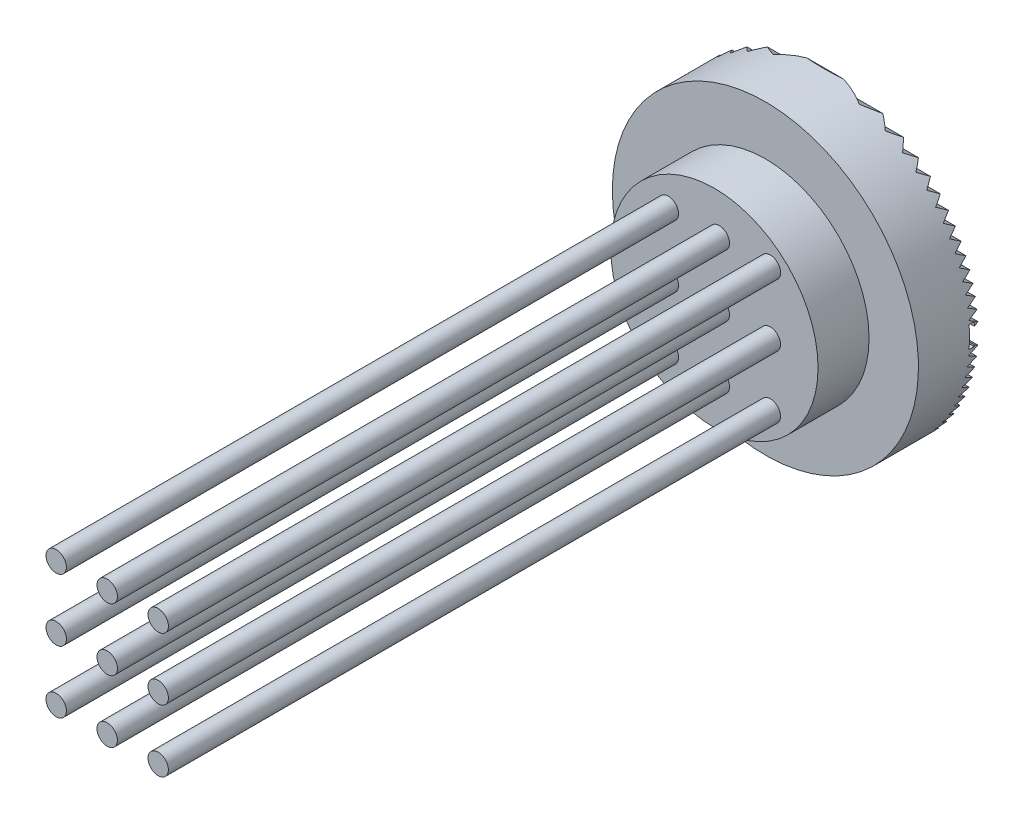
from build123d import *

# Parameters (mm, degrees)
SKETCH1_W                = 23.06
SKETCH1_H                = 21
BOSS_EXTRUDE1_DEPTH      = 4
SKETCH2_R                = 1
BOSS_EXTRUDE2_DEPTH      = 60
SKETCH3_R                = 10.161285344
BOSS_EXTRUDE3_DEPTH      = 5
SKETCH5_W                = 5.742902493
SKETCH5_H                = 25.972459016
CUT_EXTRUDE1_DEPTH       = 100
CUT_EXTRUDE1_DEPTH_BACK  = 100
SKETCH7_R                = 15
BOSS_EXTRUDE4_DEPTH      = 5
SKETCH8_W                = 2.553451716
SKETCH8_H                = 2.105839532
BOSS_EXTRUDE5_DEPTH      = 0.5
BOSS_EXTRUDE6_DEPTH      = 15.5
BOSS_EXTRUDE6_DEPTH_BACK = 22
SKETCH11_R               = 15
CUT_EXTRUDE2_DEPTH       = 15.5
CUT_EXTRUDE2_DEPTH_BACK  = 15.5


with BuildPart() as part:
    # Sketch1 → Boss-Extrude1 (new body)
    with BuildSketch(Plane.XY):
        Rectangle(SKETCH1_W, SKETCH1_H)
    extrude(amount=BOSS_EXTRUDE1_DEPTH)

    # Sketch2 → Boss-Extrude2 (add)
    with BuildSketch(Plane(origin=(0, 0, 0), x_dir=(-1, 0, 0), z_dir=(0, 0, -1))):
        with Locations((-5.48622963, -5.966693843)):
            Circle(SKETCH2_R)
        with Locations((-0.48622963, -5.966693843)):
            Circle(SKETCH2_R)
        with Locations((4.51377037, -5.966693843)):
            Circle(SKETCH2_R)
        with Locations((-0.48622963, 0.133306157)):
            Circle(SKETCH2_R)
        with Locations((4.51377037, 0.133306157)):
            Circle(SKETCH2_R)
        with Locations((-0.48622963, 6.233306157)):
            Circle(SKETCH2_R)
        with Locations((4.51377037, 6.233306157)):
            Circle(SKETCH2_R)
        with Locations((-5.48622963, 0.133306157)):
            Circle(SKETCH2_R)
        with Locations((-5.48622963, 6.233306157)):
            Circle(SKETCH2_R)
    extrude(amount=BOSS_EXTRUDE2_DEPTH)

    # Sketch3 → Boss-Extrude3 (add)
    with BuildSketch(Plane(origin=(0, 0, -60), x_dir=(-1, 0, 0), z_dir=(0, 0, -1))):
        Circle(SKETCH3_R)
    extrude(amount=BOSS_EXTRUDE3_DEPTH)

    # Sketch5 → Cut-Extrude1 (cut, two sides)
    with BuildSketch(Plane.ZY.offset(11.53)) as cut_extrude1_sk:
        with Locations((2.871451247, 2.486229508)):
            Rectangle(SKETCH5_W, SKETCH5_H)
    extrude(amount=CUT_EXTRUDE1_DEPTH, mode=Mode.SUBTRACT)
    extrude(cut_extrude1_sk.sketch, amount=-CUT_EXTRUDE1_DEPTH_BACK, mode=Mode.SUBTRACT)

    # Sketch7 → Boss-Extrude4 (add)
    with BuildSketch(Plane(origin=(0, 0, -65), x_dir=(-1, 0, 0), z_dir=(0, 0, -1))):
        Circle(SKETCH7_R)
    extrude(amount=BOSS_EXTRUDE4_DEPTH)

    # Sketch8 → Boss-Extrude5 (add)
    with BuildSketch(Plane(origin=(0, 0, -70), x_dir=(-1, 0, 0), z_dir=(0, 0, -1))):
        Rectangle(SKETCH8_W, SKETCH8_H)
    extrude(amount=BOSS_EXTRUDE5_DEPTH)

    # Sketch10 → Boss-Extrude6 (add, two sides)
    with BuildSketch(Plane(origin=(1.276725858, 0, 0), x_dir=(0, 0, -1), z_dir=(1, 0, 0))) as boss_extrude6_sk:
        Polygon((70, 13.393216219), (70.866025404, 13.893216219), (70, 14.393216219), (70.866025404, 14.893216219), (68.267949192, 16.393216219), (68.267949192, 15.393216219), (68.267949192, 14.393216219), (68.267949192, 13.393216219), (68.267949192, 12.393216219), (68.267949192, 11.393216219), (68.267949192, 10.393216219), (68.267949192, 9.393216219), (68.267949192, 8.393216219), (68.267949192, 7.393216219), (68.267949192, 6.393216219), (68.267949192, 5.393216219), (68.267949192, 4.393216219), (68.267949192, 3.393216219), (68.267949192, 2.393216219), (68.267949192, 1.393216219), (68.267949192, 0.393216219), (68.267949192, -0.606783781), (68.267949192, -1.606783781), (68.267949192, -2.606783781), (68.267949192, -3.606783781), (68.267949192, -4.606783781), (68.267949192, -5.606783781), (68.267949192, -6.606783781), (68.267949192, -7.606783781), (68.267949192, -8.606783781), (68.267949192, -9.606783781), (68.267949192, -10.606783781), (68.267949192, -11.606783781), (68.267949192, -12.606783781), (68.267949192, -13.606783781), (68.267949192, -14.606783781), (68.267949192, -15.606783781), (68.267949192, -16.606783781), (70.866025404, -15.106783781), (70, -14.606783781), (70.866025404, -14.106783781), (70, -13.606783781), (70.866025404, -13.106783781), (70, -12.606783781), (70.866025404, -12.106783781), (70, -11.606783781), (70.866025404, -11.106783781), (70, -10.606783781), (70.866025404, -10.106783781), (70, -9.606783781), (70.866025404, -9.106783781), (70, -8.606783781), (70.866025404, -8.106783781), (70, -7.606783781), (70.866025404, -7.106783781), (70, -6.606783781), (70.866025404, -6.106783781), (70, -5.606783781), (70.866025404, -5.106783781), (70, -4.606783781), (70.866025404, -4.106783781), (70, -3.606783781), (70.866025404, -3.106783781), (70, -2.606783781), (70.866025404, -2.106783781), (70, -1.606783781), (70.866025404, -1.106783781), (70.5, -0.895458916), (70.5, -1.052919766), (70, -1.052919766), (70, -0.606783781), (70, 0.393216219), (70, 1.052919766), (70.5, 1.052919766), (70.5, 0.681891354), (70.866025404, 0.893216219), (70, 1.393216219), (70.866025404, 1.893216219), (70, 2.393216219), (70.866025404, 2.893216219), (70, 3.393216219), (70.866025404, 3.893216219), (70, 4.393216219), (70.866025404, 4.893216219), (70, 5.393216219), (70.866025404, 5.893216219), (70, 6.393216219), (70.866025404, 6.893216219), (70, 7.393216219), (70.866025404, 7.893216219), (70, 8.393216219), (70.866025404, 8.893216219), (70, 9.393216219), (70.866025404, 9.893216219), (70, 10.393216219), (70.866025404, 10.893216219), (70, 11.393216219), (70.866025404, 11.893216219), (70, 12.393216219), (70.866025404, 12.893216219), align=None)
    extrude(amount=BOSS_EXTRUDE6_DEPTH)
    extrude(boss_extrude6_sk.sketch, amount=-BOSS_EXTRUDE6_DEPTH_BACK)

    # Sketch11 → Cut-Extrude2 (cut, two sides)
    with BuildSketch(Plane(origin=(0, 0, -70.5), x_dir=(-1, 0, 0), z_dir=(0, 0, -1))) as cut_extrude2_sk:
        Polygon((-16.776725858, 22.969243225), (26.614536384, 22.427014854), (20.723274142, -23.042707068), (-27.763223053, -20.563948803), align=None)
        Circle(SKETCH11_R, mode=Mode.SUBTRACT)
    extrude(amount=CUT_EXTRUDE2_DEPTH, mode=Mode.SUBTRACT)
    extrude(cut_extrude2_sk.sketch, amount=-CUT_EXTRUDE2_DEPTH_BACK, mode=Mode.SUBTRACT)


solid = part.part
